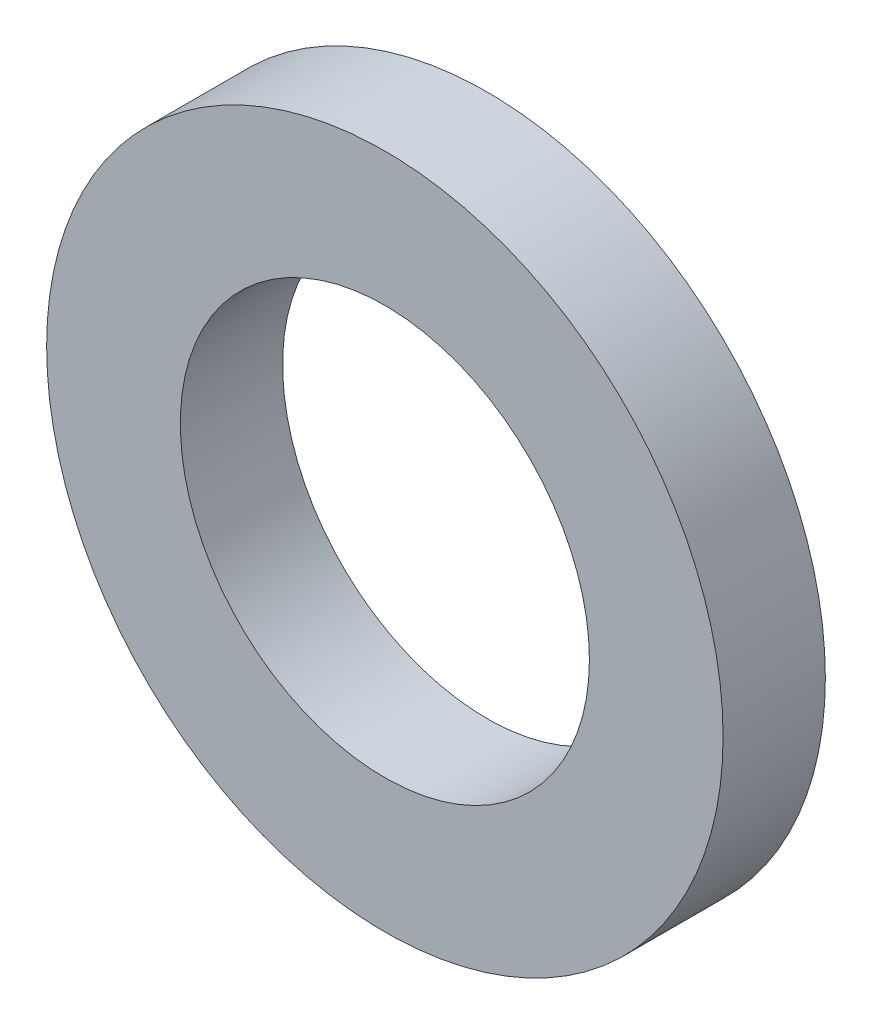
from build123d import *

# Parameters (mm, degrees)
SKETCH1_R           = 10.5
SKETCH1_R_2         = 7.5
BOSS_EXTRUDE1_DEPTH = 3.175
SKETCH2_R           = 7.5
SKETCH2_R_2         = 6.35
BOSS_EXTRUDE2_DEPTH = 3.175


with BuildPart() as part:
    # Sketch1 → Boss-Extrude1 (new body)
    with BuildSketch(Plane.XY):
        Circle(SKETCH1_R)
        Circle(SKETCH1_R_2, mode=Mode.SUBTRACT)
    extrude(amount=BOSS_EXTRUDE1_DEPTH)

    # Sketch2 → Boss-Extrude2 (add)
    with BuildSketch(Plane.XY):
        Circle(SKETCH2_R)
        Circle(SKETCH2_R_2, mode=Mode.SUBTRACT)
    extrude(amount=BOSS_EXTRUDE2_DEPTH)


solid = part.part
